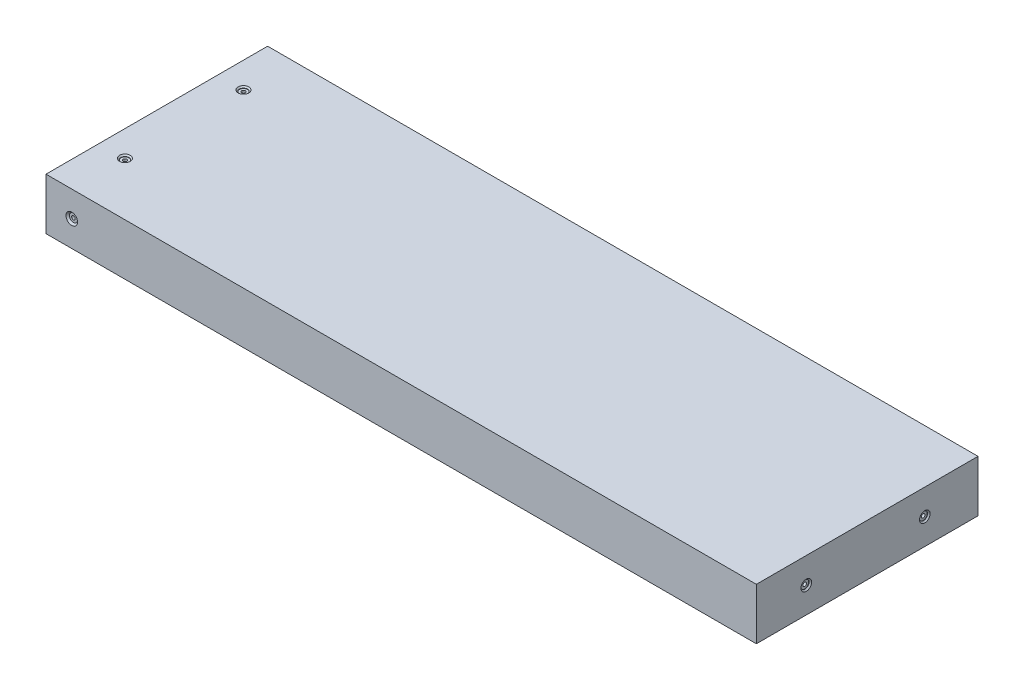
from build123d import *

# Parameters (mm, degrees)
SKETCH1_W                                   = 350
SKETCH1_H                                   = 109.2
BOSS_EXTRUDE1_DEPTH                         = 25.4
CBORE_FOR_0_BINDING_HEAD_MACHINE_SC_2_COUNT = 2
CBORE_FOR_0_BINDING_HEAD_MACHINE_SC_2_PITCH = 58.4
CBORE_FOR_0_BINDING_HEAD_MACHINE_SC_3_COUNT = 2
CBORE_FOR_0_BINDING_HEAD_MACHINE_SC_3_PITCH = 58.4


with BuildPart() as part:
    # Sketch1 → Boss-Extrude1 (new body)
    with BuildSketch(Plane(origin=(0, 0, 0), x_dir=(1, 0, 0), z_dir=(0, 1, 0))):
        Rectangle(SKETCH1_W, SKETCH1_H)
    extrude(amount=BOSS_EXTRUDE1_DEPTH)

    # Sketch3 → CBORE for #0 Binding Head Machine Screw1 (revolve, cut)
    with BuildSketch(Plane(origin=(-162.3, 12.7, 54.6), x_dir=(0, -1, 0), z_dir=(1, 0, 0))):
        Polygon((0, 0), (0, 30.53416509), (0.889, 30), (0.889, 0.8128), (1.98501, 0.8128), (1.98501, 0.87249), (2.8575, 0), align=None)
    cbore_for_0_binding_head_machine_screw1 = revolve(axis=Axis((-162.3, 12.7, 60.95), (0, 0, -1)), mode=Mode.SUBTRACT)

    # Mirror1: CBORE for #0 Binding Head Machine Screw1 across plane
    add(cbore_for_0_binding_head_machine_screw1.mirror(Plane.XY), mode=Mode.SUBTRACT)

    # Sketch5 → CBORE for #0 Binding Head Machine Screw2 (revolve, cut)
    with BuildSketch(Plane(origin=(175, 12.7, 30), x_dir=(0, 0, -1), z_dir=(0, 1, 0))):
        Polygon((0, 0), (0, 30.53416509), (0.889, 30), (0.889, 0.8128), (1.98501, 0.8128), (1.98501, 0.635), (2.62001, 0), align=None)
    cbore_for_0_binding_head_machine_screw2 = revolve(axis=Axis((181.35, 12.7, 30), (-1, 0, 0)), mode=Mode.SUBTRACT)

    # CBORE for _0 Binding Head Machine Sc 2: CBORE for #0 Binding Head Machine Screw2 ×2
    with Locations(*[(0, 0, -i * CBORE_FOR_0_BINDING_HEAD_MACHINE_SC_2_PITCH) for i in range(1, CBORE_FOR_0_BINDING_HEAD_MACHINE_SC_2_COUNT)]):
        add(cbore_for_0_binding_head_machine_screw2, mode=Mode.SUBTRACT)

    # Sketch7 → CBORE for #0 Binding Head Machine Screw3 (revolve, cut)
    with BuildSketch(Plane(origin=(-162.3, 25.4, -30), x_dir=(0, 0, 1), z_dir=(1, 0, 0))):
        Polygon((0, 0), (0, 30.53416509), (0.889, 30), (0.889, 0.8128), (1.98501, 0.8128), (1.98501, 0.635), (2.62001, 0), align=None)
    cbore_for_0_binding_head_machine_screw3 = revolve(axis=Axis((-162.3, 31.75, -30), (0, -1, 0)), mode=Mode.SUBTRACT)

    # CBORE for _0 Binding Head Machine Sc 3: CBORE for #0 Binding Head Machine Screw3 ×2
    with Locations(*[(0, 0, i * CBORE_FOR_0_BINDING_HEAD_MACHINE_SC_3_PITCH) for i in range(1, CBORE_FOR_0_BINDING_HEAD_MACHINE_SC_3_COUNT)]):
        add(cbore_for_0_binding_head_machine_screw3, mode=Mode.SUBTRACT)


solid = part.part
